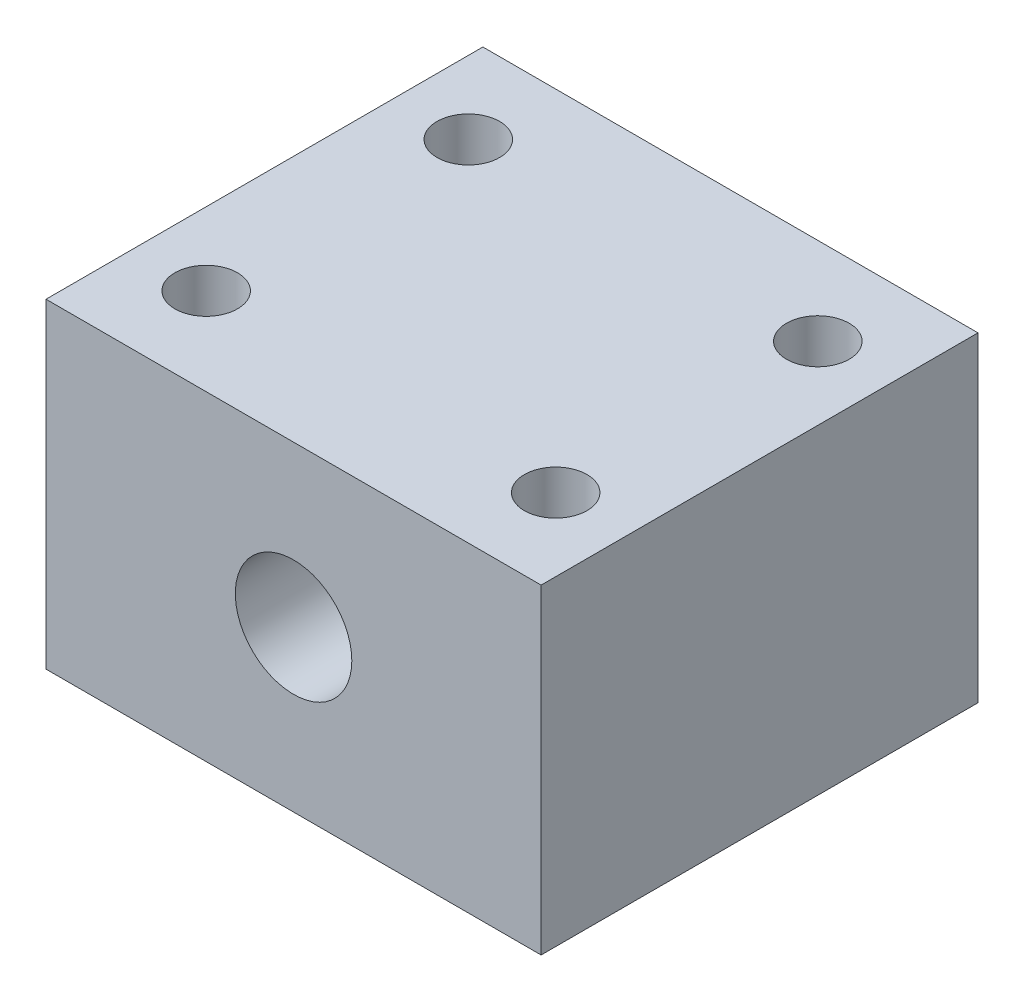
from build123d import *

# Parameters (mm, degrees)
SKETCH_1_W          = 34
SKETCH_1_H          = 30
EXTRUDE_1_DEPTH     = 22
SKETCH_2_R          = 2.15
CUT_EXTRUDE_1_DEPTH = 23
SKETCH_3_R          = 4
CUT_EXTRUDE_2_DEPTH = 31


with BuildPart() as part:
    # 草图1 → 凸台-拉伸1 (new body)
    with BuildSketch(Plane(origin=(0, 0, 0), x_dir=(1, 0, 0), z_dir=(0, 1, 0))):
        Rectangle(SKETCH_1_W, SKETCH_1_H)
    extrude(amount=EXTRUDE_1_DEPTH)

    # 草图2 → 切除-拉伸1 (cut, through all)
    with BuildSketch(Plane(origin=(0, 22, 0), x_dir=(1, 0, 0), z_dir=(0, 1, 0))):
        with Locations((-12, 9)):
            Circle(SKETCH_2_R)
        with Locations((12, 9)):
            Circle(SKETCH_2_R)
        with Locations((12, -9)):
            Circle(SKETCH_2_R)
        with Locations((-12, -9)):
            Circle(SKETCH_2_R)
    extrude(amount=-CUT_EXTRUDE_1_DEPTH, mode=Mode.SUBTRACT)

    # 草图3 → 切除-拉伸2 (cut, through all)
    with BuildSketch(Plane.XY.offset(15)):
        with Locations((0, 11)):
            Circle(SKETCH_3_R)
    extrude(amount=-CUT_EXTRUDE_2_DEPTH, mode=Mode.SUBTRACT)


solid = part.part
